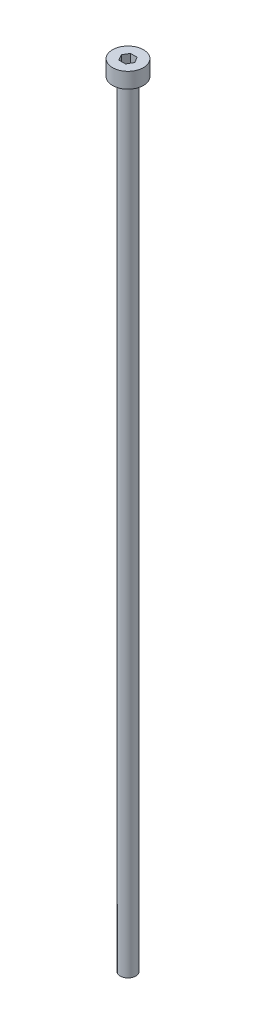
from build123d import *

# Parameters (mm, degrees)
SKETCH_1_R            = 2
EXTRUDE_246_DEPTH     = 2
CUT_EXTRUDE_376_DEPTH = 1.5
SKETCH_3_R            = 1
EXTRUDE_477_DEPTH     = 100


with BuildPart() as part:
    # 草图1 → Extrude 246 (new body)
    with BuildSketch(Plane(origin=(0, 0, 0), x_dir=(1, 0, 0), z_dir=(0, 1, 0))):
        Circle(SKETCH_1_R)
    extrude(amount=EXTRUDE_246_DEPTH)

    # 草图2 → Cut-Extrude 376 (cut)
    with BuildSketch(Plane(origin=(0, 2, 0), x_dir=(1, 0, 0), z_dir=(0, 1, 0))):
        Polygon((0.866025404, 0), (0.433012702, 0.75), (-0.433012702, 0.75), (-0.866025404, 0), (-0.433012702, -0.75), (0.433012702, -0.75), align=None)
    extrude(amount=-CUT_EXTRUDE_376_DEPTH, mode=Mode.SUBTRACT)

    # 草图3 → Extrude 477 (add)
    with BuildSketch(Plane.XZ):
        Circle(SKETCH_3_R)
    extrude(amount=EXTRUDE_477_DEPTH)


solid = part.part
